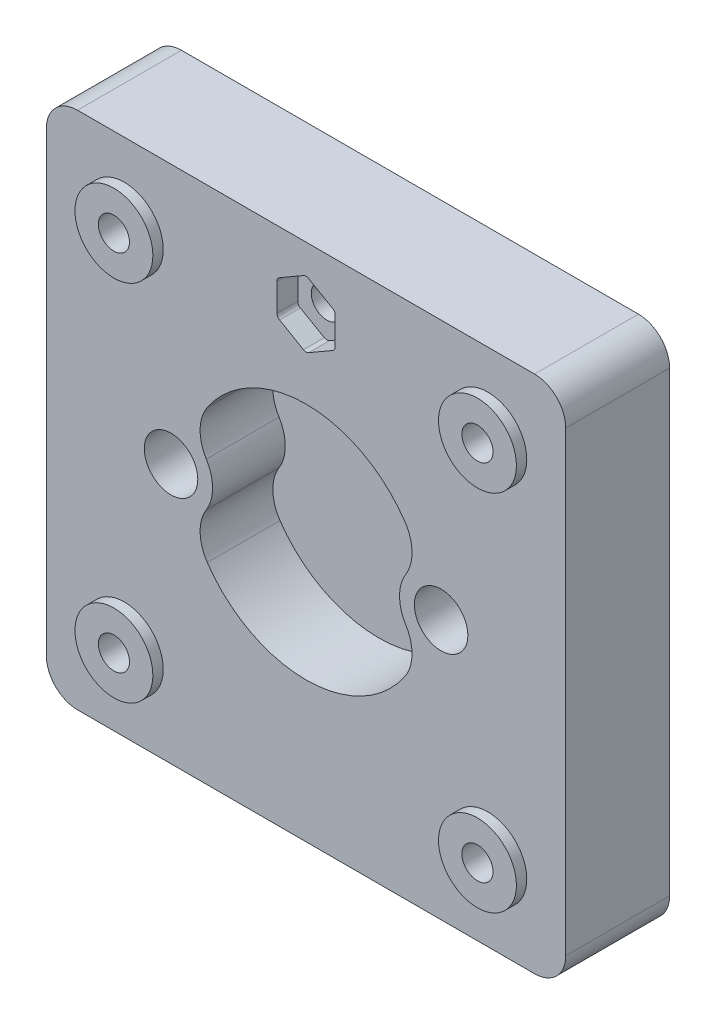
from build123d import *

# Parameters (mm, degrees)
SKETCH1_W               = 50
SKETCH1_H               = 50
BODY_DEPTH              = 10
SKETCH2_R               = 11.5
CUT_VIEW_DEPTH          = 7
FILLETBODY_R            = 3
SKETCH3_R               = 3.75
BOLT_EXTRUDE_DEPTH      = 1
SKETCH4_R               = 1.5
BOLT_DEPTH              = 10
BOLT_DEPTH_BACK         = 16
HEX_2_DEPTH             = 2
SKETCH19_R              = 1.5
HEX_BOLT_DEPTH          = 3
SKETCH6_R               = 4
FIELD1_DEPTH            = 7
FIELD2_R                = 4
SKETCH7_R               = 2.575
PORTS1_DEPTH            = 12
SKETCH10_R              = 1.575
PORTS2_DEPTH            = 12
PORTS2_DEPTH_BACK       = 32
SKETCH11_R              = 20
SKETCH11_R_2            = 15
SEAL1_DEPTH             = 0.5
FLOWFIELD_DEPTH         = 1.5
FLOWFIELD_CHANNEL_DEPTH = 1.5
BODY_MOVE_COPY1_ANGLE   = 90
SKETCH20_R              = 2.575
CUT_EXTRUDE1_DEPTH      = 17
FILLET1_R               = 0.5


with BuildPart() as part:
    # Sketch1 → Body (new body)
    with BuildSketch(Plane(origin=(0, 0, 0), x_dir=(1, 0, 0), z_dir=(0, 1, 0))):
        Rectangle(SKETCH1_W, SKETCH1_H)
    extrude(amount=BODY_DEPTH)

    # Sketch2 → Cut view (cut)
    with BuildSketch(Plane(origin=(0, 10, 0), x_dir=(1, 0, 0), z_dir=(0, 1, 0))):
        Circle(SKETCH2_R)
    extrude(amount=-CUT_VIEW_DEPTH, mode=Mode.SUBTRACT)

    # FilletBody
    filletbody_edges = [part.edges().sort_by_distance(p)[0] for p in [
        (-25, 5, -25),
        (25, 5, -25),
        (25, 5, 25),
        (-25, 5, 25),
    ]]
    fillet(filletbody_edges, radius=FILLETBODY_R)

    # Sketch3 → Bolt extrude (add)
    with BuildSketch(Plane(origin=(0, 10, 0), x_dir=(1, 0, 0), z_dir=(0, 1, 0))):
        with Locations((-17.5, 17.5)):
            Circle(SKETCH3_R)
        with Locations((17.5, 17.5)):
            Circle(SKETCH3_R)
        with Locations((17.5, -17.5)):
            Circle(SKETCH3_R)
        with Locations((-17.5, -17.5)):
            Circle(SKETCH3_R)
    extrude(amount=BOLT_EXTRUDE_DEPTH)

    # Sketch4 → Bolt (cut, two sides)
    with BuildSketch(Plane(origin=(0, 11, 0), x_dir=(1, 0, 0), z_dir=(0, 1, 0))) as bolt_sk:
        with Locations((-17.5, 17.5)):
            Circle(SKETCH4_R)
        with Locations((17.5, 17.5)):
            Circle(SKETCH4_R)
        with Locations((17.5, -17.5)):
            Circle(SKETCH4_R)
        with Locations((-17.5, -17.5)):
            Circle(SKETCH4_R)
    extrude(amount=BOLT_DEPTH, mode=Mode.SUBTRACT)
    extrude(bolt_sk.sketch, amount=-BOLT_DEPTH_BACK, mode=Mode.SUBTRACT)

    # Sketch5 → Hex 2 (cut)
    with BuildSketch(Plane(origin=(0, 10, 0), x_dir=(1, 0, 0), z_dir=(0, 1, 0))):
        Polygon((0, 22.233161507), (-2.8, 20.616580754), (-2.8, 17.383419246), (0, 15.766838493), (2.8, 17.383419246), (2.8, 20.616580754), align=None)
    extrude(amount=-HEX_2_DEPTH, mode=Mode.SUBTRACT)

    # Sketch19 → Hex_bolt (cut)
    with BuildSketch(Plane(origin=(0, 8, 0), x_dir=(1, 0, 0), z_dir=(0, 1, 0))):
        with Locations((0, 19)):
            Circle(SKETCH19_R)
    extrude(amount=-HEX_BOLT_DEPTH, mode=Mode.SUBTRACT)

    # Sketch6 → Field1 (add)
    with BuildSketch(Plane(origin=(0, 10, 0), x_dir=(1, 0, 0), z_dir=(0, 1, 0))):
        with Locations((-13, 0)):
            Circle(SKETCH6_R)
        with Locations((13, 0)):
            Circle(SKETCH6_R)
    extrude(amount=-FIELD1_DEPTH)

    # Field2
    field2_edges = [part.edges().sort_by_distance(p)[0] for p in [
        (-10.971153846, 6.5, 3.447286365),
        (-10.971153846, 6.5, -3.447286365),
        (10.971153846, 6.5, -3.447286365),
        (10.971153846, 6.5, 3.447286365),
    ]]
    fillet(field2_edges, radius=FIELD2_R)

    # Sketch7 → Ports1 (add)
    with BuildSketch(Plane(origin=(0, 10, 0), x_dir=(1, 0, 0), z_dir=(0, 1, 0))):
        with Locations((-13, 0)):
            Circle(SKETCH7_R)
        with Locations((13, 0)):
            Circle(SKETCH7_R)
    extrude(amount=PORTS1_DEPTH)

    # Sketch10 → Ports2 (cut, two sides)
    with BuildSketch(Plane(origin=(0, 22, 0), x_dir=(1, 0, 0), z_dir=(0, 1, 0))) as ports2_sk:
        with Locations((-13, 0)):
            Circle(SKETCH10_R)
        with Locations((13, 0)):
            Circle(SKETCH10_R)
    extrude(amount=PORTS2_DEPTH, mode=Mode.SUBTRACT)
    extrude(ports2_sk.sketch, amount=-PORTS2_DEPTH_BACK, mode=Mode.SUBTRACT)

    # Sketch11 → Seal1 (cut)
    with BuildSketch(Plane.XZ):
        Circle(SKETCH11_R)
        Circle(SKETCH11_R_2, mode=Mode.SUBTRACT)
    extrude(amount=-SEAL1_DEPTH, mode=Mode.SUBTRACT)

    # Sketch15 → FlowField (cut)
    with BuildSketch(Plane.XZ):
        with BuildLine():
            ThreePointArc((13.522961568, 3.623466631), (-1.199537572, 13.948516395), (-13.943052885, 1.261457989))
            ThreePointArc((-13.943052885, 1.261457989), (-12.926234652, 1.573271646), (-11.943052885, 1.167684801))
            ThreePointArc((-11.943052885, 1.167684801), (-0.984919414, 11.95951227), (11.591109915, 3.105828541))
            ThreePointArc((11.591109915, 3.105828541), (12.815854787, 2.39872176), (13.522961568, 3.623466631))
        make_face()
        with BuildLine():
            ThreePointArc((11, 0), (1.910129954, 10.832885283), (-10.336618829, 3.762221577))
            ThreePointArc((-10.336618829, 3.762221577), (-9.738946351, 2.480508812), (-8.457233587, 3.07818129))
            ThreePointArc((-8.457233587, 3.07818129), (1.562833599, 8.863269777), (9, 0))
            Line((9, 0), (11, 0))
        make_face()
        with BuildLine():
            ThreePointArc((7.250462296, 3.380946094), (6.766772771, 2.052020045), (5.437846722, 2.53570957))
            ThreePointArc((5.437846722, 2.53570957), (-1.298637684, 5.857776043), (-6, 0))
            Line((-6, 0), (-8, 0))
            ThreePointArc((-8, 0), (-1.731516912, 7.810368057), (7.250462296, 3.380946094))
        make_face()
        with BuildLine():
            ThreePointArc((5, 0), (1.913417162, 4.619397663), (-3.535533906, 3.535533906))
            ThreePointArc((-3.535533906, 3.535533906), (-3.535533906, 2.121320344), (-2.121320344, 2.121320344))
            ThreePointArc((-2.121320344, 2.121320344), (1.148050297, 2.771638598), (3, 0))
            Line((3, 0), (5, 0))
        make_face()
        with BuildLine():
            ThreePointArc((5, 0), (1.913417162, -4.619397663), (-3.535533906, -3.535533906))
            ThreePointArc((-3.535533906, -3.535533906), (-3.535533906, -2.121320344), (-2.121320344, -2.121320344))
            ThreePointArc((-2.121320344, -2.121320344), (1.148050297, -2.771638598), (3, 0))
            Line((3, 0), (5, 0))
        make_face()
        with BuildLine():
            ThreePointArc((-8, 0), (-1.731516912, -7.810368057), (7.250462296, -3.380946094))
            ThreePointArc((7.250462296, -3.380946094), (6.766772771, -2.052020045), (5.437846722, -2.53570957))
            ThreePointArc((5.437846722, -2.53570957), (-1.298637684, -5.857776043), (-6, 0))
            Line((-6, 0), (-8, 0))
        make_face()
        with BuildLine():
            ThreePointArc((11, 0), (1.910129954, -10.832885283), (-10.336618829, -3.762221577))
            ThreePointArc((-10.336618829, -3.762221577), (-9.738946351, -2.480508812), (-8.457233587, -3.07818129))
            ThreePointArc((-8.457233587, -3.07818129), (1.562833599, -8.863269777), (9, 0))
            Line((9, 0), (11, 0))
        make_face()
        with BuildLine():
            ThreePointArc((-11.943052885, -1.167684801), (-12.926234652, -1.573271646), (-13.943052885, -1.261457989))
            ThreePointArc((-13.943052885, -1.261457989), (-1.199537572, -13.948516395), (13.522961568, -3.623466631))
            ThreePointArc((13.522961568, -3.623466631), (12.815854787, -2.39872176), (11.591109915, -3.105828541))
            ThreePointArc((11.591109915, -3.105828541), (-0.984919414, -11.95951227), (-11.943052885, -1.167684801))
        make_face()
    extrude(amount=-FLOWFIELD_DEPTH, mode=Mode.SUBTRACT)

    # Sketch16 → FlowField_Channel (cut)
    with BuildSketch(Plane.XZ):
        with BuildLine():
            Line((-13, 1), (0, 1))
            ThreePointArc((0, 1), (1, 0), (0, -1))
            Line((0, -1), (-13, -1))
            ThreePointArc((-13, -1), (-14, 0), (-13, 1))
        make_face()
        with BuildLine():
            Line((13, -1), (4.429119544, -1))
            ThreePointArc((4.429119544, -1), (3.429119544, 0), (4.429119544, 1))
            Line((4.429119544, 1), (13, 1))
            ThreePointArc((13, 1), (14, 0), (13, -1))
        make_face()
    extrude(amount=-FLOWFIELD_CHANNEL_DEPTH, mode=Mode.SUBTRACT)


with BuildPart() as part_1:
    # Body-Move/Copy1: moved
    add(part.part.rotate(Axis((0, 11, 0), (1, 0, 0)), BODY_MOVE_COPY1_ANGLE))

    # Sketch20 → Cut-Extrude1 (cut)
    with BuildSketch(Plane.XY.offset(11)):
        with Locations((13, 11)):
            Circle(SKETCH20_R)
        with Locations((-13, 11)):
            Circle(SKETCH20_R)
    extrude(amount=-CUT_EXTRUDE1_DEPTH, mode=Mode.SUBTRACT)

    # Fillet1
    fillet1_edges = [part_1.edges().sort_by_distance(p)[0] for p in [
        (0, 33.233161507, -2),
        (2.8, 31.616580754, -2),
        (2.8, 28.383419246, -2),
        (0, 26.766838493, -2),
        (-2.8, 28.383419246, -2),
        (-2.8, 31.616580754, -2),
    ]]
    fillet(fillet1_edges, radius=FILLET1_R)


solid = part_1.part
